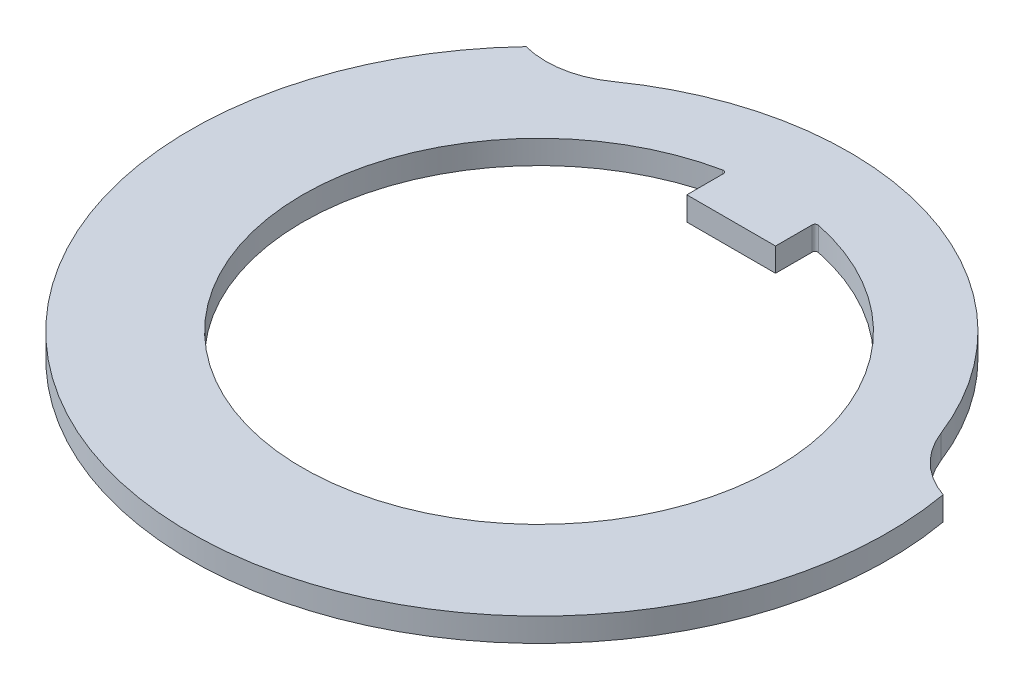
from build123d import *

# Parameters (mm, degrees)
BOSS_EXTRUDE1_DEPTH = 0.8
FILLET1_R           = 0.1


with BuildPart() as part:
    # Sketch1 → Boss-Extrude1 (new body)
    with BuildSketch(Plane(origin=(0, 0, 0), x_dir=(1, 0, 0), z_dir=(0, 1, 0))):
        with BuildLine():
            ThreePointArc((9.786805864, 3.803739078), (3.026060815, 10.054499288), (-6.061654374, 8.573584213))
            ThreePointArc((-6.061654374, 8.573584213), (-7.260490637, 8.07091926), (-8.559417578, 8.122583993))
            ThreePointArc((-8.559417578, 8.122583993), (-3.400715964, -11.299342057), (11.620731486, 2.049048496))
            ThreePointArc((11.620731486, 2.049048496), (10.509059049, 2.722891827), (9.786805864, 3.803739078))
        make_face()
        with BuildLine():
            Line((-1.5, 6.5), (1.5, 6.5))
            Line((1.5, 6.5), (1.5, 7.858116823))
            ThreePointArc((1.5, 7.858116823), (0, -8), (-1.5, 7.858116823))
            Line((-1.5, 7.858116823), (-1.5, 6.5))
        make_face(mode=Mode.SUBTRACT)
    extrude(amount=BOSS_EXTRUDE1_DEPTH)

    # Fillet1
    fillet1_edges = [part.edges().sort_by_distance(p)[0] for p in [
        (-1.5, 0.4, -7.858116823),
        (1.5, 0.4, -7.858116823),
    ]]
    fillet(fillet1_edges, radius=FILLET1_R)


solid = part.part
